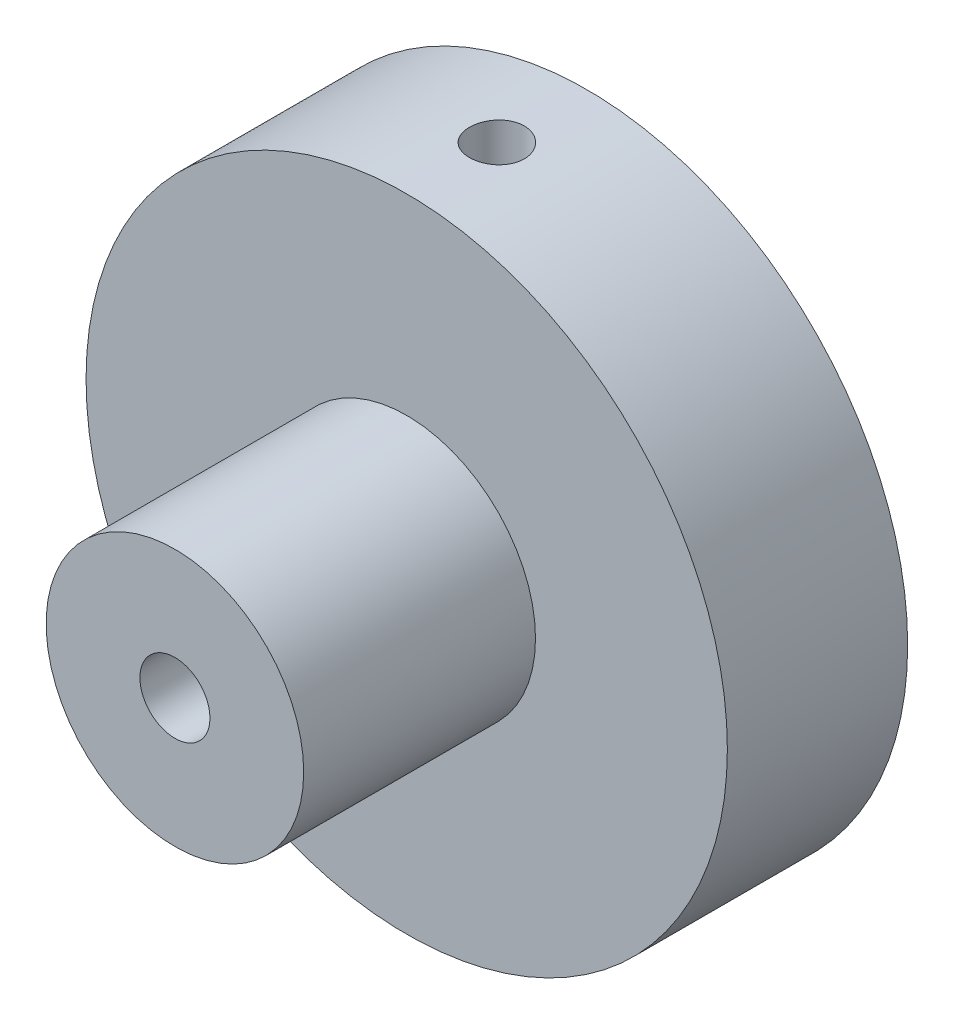
from build123d import *

# Parameters (mm, degrees)
SKETCH1_R                 = 15.8115
BOSS_EXTRUDE1_DEPTH       = 25.4
SKETCH2_OUTSIDE_W         = 43.91
SKETCH2_OUTSIDE_H         = 43.91
SKETCH2_OUTSIDE_R         = 6.35
CUT_EXTRUDE1_DEPTH        = 16.51
F_8_32_TAPPED_HOLE1_D     = 3.4544
F_6_32_TAPPED_HOLE2_D     = 2.7051
F_6_32_TAPPED_HOLE2_DEPTH = 6.858
F_6_32_TAPPED_HOLE2_TIP   = 0.81269403
F_6_32_TAPPED_HOLE3_D     = 2.7051
F_6_32_TAPPED_HOLE3_DEPTH = 6.096
F_6_32_TAPPED_HOLE3_TIP   = 0.81269403
SKETCH9_R                 = 6.35
CUT_EXTRUDE3_DEPTH        = 5.08


with BuildPart() as part:
    # Sketch1 → Boss-Extrude1 (new body)
    with BuildSketch(Plane.XY):
        Circle(SKETCH1_R)
    extrude(amount=BOSS_EXTRUDE1_DEPTH)

    # Sketch2 outside → Cut-Extrude1 (cut)
    with BuildSketch(Plane.XY.offset(25.4)):
        Rectangle(SKETCH2_OUTSIDE_W, SKETCH2_OUTSIDE_H)
        Circle(SKETCH2_OUTSIDE_R, mode=Mode.SUBTRACT)
    extrude(amount=-CUT_EXTRUDE1_DEPTH, mode=Mode.SUBTRACT)

    # #8-32 Tapped Hole1 (through all)
    with Locations(Plane.XY.offset(25.4)):
        with Locations((0, 0)):
            Hole(F_8_32_TAPPED_HOLE1_D / 2)

    # #6-32 Tapped Hole2
    with Locations(Plane(origin=(0, 0, 0), x_dir=(-1, 0, 0), z_dir=(0, 0, -1))):
        with Locations((-6.35, 0), (6.35, 0)):
            Hole(F_6_32_TAPPED_HOLE2_D / 2, depth=F_6_32_TAPPED_HOLE2_DEPTH)
            with Locations((0, 0, -(F_6_32_TAPPED_HOLE2_DEPTH + F_6_32_TAPPED_HOLE2_TIP / 2))):  # 118° drill point
                Cone(0, F_6_32_TAPPED_HOLE2_D / 2, F_6_32_TAPPED_HOLE2_TIP, mode=Mode.SUBTRACT)

    # #6-32 Tapped Hole3
    with Locations(Plane(origin=(0, 15.8115, 4.445), x_dir=(1, 0, 0), z_dir=(0, 1, 0))):
        with Locations((0, 0)):
            Hole(F_6_32_TAPPED_HOLE3_D / 2, depth=F_6_32_TAPPED_HOLE3_DEPTH)
            with Locations((0, 0, -(F_6_32_TAPPED_HOLE3_DEPTH + F_6_32_TAPPED_HOLE3_TIP / 2))):  # 118° drill point
                Cone(0, F_6_32_TAPPED_HOLE3_D / 2, F_6_32_TAPPED_HOLE3_TIP, mode=Mode.SUBTRACT)

    # Sketch9 → Cut-Extrude3 (cut)
    with BuildSketch(Plane.XY.offset(25.4)):
        Circle(SKETCH9_R)
    extrude(amount=-CUT_EXTRUDE3_DEPTH, mode=Mode.SUBTRACT)


solid = part.part
